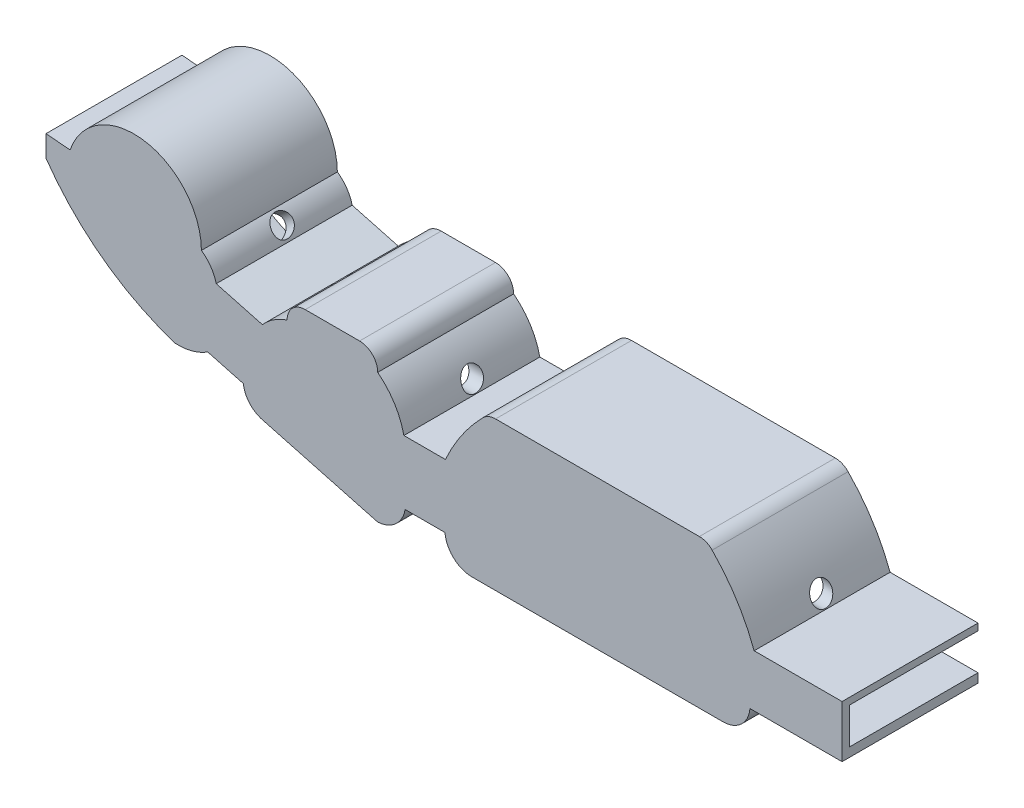
from build123d import *

# Parameters (mm, degrees)
WALLS_DEPTH         = 16
BASE_DEPTH          = 1
CUT_EXTRUDE2_START  = 3.037206
SKETCH14_R          = 1.4
CUT_EXTRUDE2_DEPTH  = 11.746553
CUT_EXTRUDE3_REACH  = 97.922
SKETCH15_R          = 1.4
CUT_EXTRUDE4_START  = -13.606104
SKETCH16_R          = 1.4
CUT_EXTRUDE4_DEPTH  = 14.101179
CUT_EXTRUDE5_REACH  = 79.266
SKETCH18_R          = 1.4
CUT_EXTRUDE6_DEPTH  = 1
CUT_EXTRUDE7_START  = 1
SKETCH20_W          = 0.5
SKETCH20_H          = 5.968950485
CUT_EXTRUDE7_DEPTH  = 13
CUT_EXTRUDE8_START  = -1
SKETCH21_W          = 1.2
SKETCH21_H          = 4.8
CUT_EXTRUDE8_DEPTH  = 17
BOSS_EXTRUDE7_DEPTH = 1


with BuildPart() as part:
    # Sketch1 → Walls (new body)
    with BuildSketch(Plane.XY):
        with BuildLine():
            Line((-2.714226626, -4.104973799), (9.481662569, -4.104973799))
            Line((9.481662569, -4.104973799), (9.481662569, 2.795026201))
            Line((9.481662569, 2.795026201), (-2.157765014, 2.795026201))
            ThreePointArc((-2.157765014, 2.795026201), (-4.475421171, 7.467506564), (-7.720187416, 11.551021571))
            ThreePointArc((-7.720187416, 11.551021571), (-8.494484922, 12.081481284), (-9.414311331, 12.268145448))
            Line((-9.414311331, 12.268145448), (-36.393543444, 12.262464463))
            ThreePointArc((-36.393543444, 12.262464463), (-37.313369853, 12.075800298), (-38.087667358, 11.545340586))
            ThreePointArc((-38.087667358, 11.545340586), (-40.886844781, 8.138526492), (-43.037560944, 4.289345216))
            Line((-43.037560944, 4.289345216), (-48.534846494, 4.289345216))
            ThreePointArc((-48.534846494, 4.289345216), (-49.785555134, 7.346558362), (-52.000729869, 9.796828799))
            ThreePointArc((-52.000729869, 9.796828799), (-52.703673594, 11.493885073), (-54.400729869, 12.196828799))
            Line((-54.400729869, 12.196828799), (-61.600729869, 12.196828799))
            ThreePointArc((-61.600729869, 12.196828799), (-63.297786144, 11.493885073), (-64.000729869, 9.796828799))
            ThreePointArc((-64.000729869, 9.796828799), (-65.78162874, 8.936932107), (-67.269416799, 7.634046924))
            Line((-67.269416799, 7.634046924), (-73.381930249, 9.274434959))
            ThreePointArc((-73.381930249, 9.274434959), (-74.102271118, 10.871911924), (-75.343349149, 12.109065488))
            ThreePointArc((-75.343349149, 12.109065488), (-82.839508973, 20.890555052), (-92.73395996, 14.940192817))
            Line((-92.73395996, 14.940192817), (-95.922420017, 15.211711628))
            Line((-95.922420017, 15.211711628), (-95.922420017, 12.380143838))
            ThreePointArc((-95.922420017, 12.380143838), (-88.403090993, 4.657382588), (-78.817826716, -0.272532121))
            ThreePointArc((-78.817826716, -0.272532121), (-76.571233378, -0.037510666), (-74.506694684, 0.879057219))
            Line((-74.506694684, 0.879057219), (-72.20946266, 0.262559283))
            Line((-72.20946266, 0.262559283), (-69.801914295, -0.383543758))
            ThreePointArc((-69.801914295, -0.383543758), (-68.910263869, -2.291103836), (-67.07577957, -3.324783328))
            Line((-67.07577957, -3.324783328), (-52.008906119, -7.36821311))
            ThreePointArc((-52.008906119, -7.36821311), (-49.620072822, -6.375064761), (-48.368947082, -4.110654784))
            Line((-48.368947082, -4.110654784), (-43.097948822, -4.110654784))
            ThreePointArc((-43.097948822, -4.110654784), (-41.950292784, -6.466194573), (-39.509720692, -7.419761527))
            Line((-39.509720692, -7.419761527), (-6.302454756, -7.414080542))
            ThreePointArc((-6.302454756, -7.414080542), (-3.861882663, -6.460513587), (-2.714226626, -4.104973799))
        make_face()
        with BuildLine():
            Line((-11.180694354, 10.652027), (-11.480694354, 9.152027))
            Line((-11.480694354, 9.152027), (-11.780694354, 10.652027))
            Line((-11.780694354, 10.652027), (-12.480694354, 10.652027))
            Line((-12.480694354, 10.652027), (-12.780694354, 9.152027))
            Line((-12.780694354, 9.152027), (-13.080694354, 10.652027))
            Line((-13.080694354, 10.652027), (-13.754684343, 10.652027))
            Line((-13.754684343, 10.652027), (-14.054684343, 9.152027))
            Line((-14.054684343, 9.152027), (-14.354684343, 10.652027))
            Line((-14.354684343, 10.652027), (-15.054684343, 10.652027))
            Line((-15.054684343, 10.652027), (-15.354684343, 9.152027))
            Line((-15.354684343, 9.152027), (-15.654684343, 10.652027))
            Line((-15.654684343, 10.652027), (-16.354684343, 10.652027))
            Line((-16.354684343, 10.652027), (-16.654684343, 9.152027))
            Line((-16.654684343, 9.152027), (-16.954684343, 10.652027))
            Line((-16.954684343, 10.652027), (-17.654684343, 10.652027))
            Line((-17.654684343, 10.652027), (-17.954684343, 9.152027))
            Line((-17.954684343, 9.152027), (-18.254684343, 10.652027))
            Line((-18.254684343, 10.652027), (-18.954684343, 10.652027))
            Line((-18.954684343, 10.652027), (-19.254684343, 9.152027))
            Line((-19.254684343, 9.152027), (-19.554684343, 10.652027))
            Line((-19.554684343, 10.652027), (-20.254684343, 10.652027))
            Line((-20.254684343, 10.652027), (-20.554684343, 9.152027))
            Line((-20.554684343, 9.152027), (-20.854684343, 10.652027))
            Line((-20.854684343, 10.652027), (-21.554684343, 10.652027))
            Line((-21.554684343, 10.652027), (-21.854684343, 9.152027))
            Line((-21.854684343, 9.152027), (-22.154684343, 10.652027))
            Line((-22.154684343, 10.652027), (-22.854684343, 10.652027))
            Line((-22.854684343, 10.652027), (-23.154684343, 9.152027))
            Line((-23.154684343, 9.152027), (-23.454684343, 10.652027))
            Line((-23.454684343, 10.652027), (-24.154684343, 10.652027))
            Line((-24.154684343, 10.652027), (-24.454684343, 9.152027))
            Line((-24.454684343, 9.152027), (-24.754684343, 10.652027))
            Line((-24.754684343, 10.652027), (-25.454684343, 10.652027))
            Line((-25.454684343, 10.652027), (-25.754684343, 9.152027))
            Line((-25.754684343, 9.152027), (-26.054684343, 10.652027))
            Line((-26.054684343, 10.652027), (-26.754684343, 10.652027))
            Line((-26.754684343, 10.652027), (-27.054684343, 9.152027))
            Line((-27.054684343, 9.152027), (-27.354684343, 10.652027))
            Line((-27.354684343, 10.652027), (-28.054684343, 10.652027))
            Line((-28.054684343, 10.652027), (-28.354684343, 9.152027))
            Line((-28.354684343, 9.152027), (-28.654684343, 10.652027))
            Line((-28.654684343, 10.652027), (-29.354684343, 10.652027))
            Line((-29.354684343, 10.652027), (-29.654684343, 9.152027))
            Line((-29.654684343, 9.152027), (-29.954684343, 10.652027))
            Line((-29.954684343, 10.652027), (-30.654684343, 10.652027))
            Line((-30.654684343, 10.652027), (-30.954684343, 9.152027))
            Line((-30.954684343, 9.152027), (-31.254684343, 10.652027))
            Line((-31.254684343, 10.652027), (-31.954684343, 10.652027))
            Line((-31.954684343, 10.652027), (-32.254684343, 9.152027))
            Line((-32.254684343, 9.152027), (-32.554684343, 10.652027))
            Line((-32.554684343, 10.652027), (-33.254684343, 10.652027))
            Line((-33.254684343, 10.652027), (-33.554684343, 9.152027))
            Line((-33.554684343, 9.152027), (-33.854684343, 10.652027))
            Line((-33.854684343, 10.652027), (-34.554684343, 10.652027))
            Line((-34.554684343, 10.652027), (-34.854684343, 9.152027))
            Line((-34.854684343, 9.152027), (-35.154684343, 10.652027))
            Line((-35.154684343, 10.652027), (-35.854684343, 10.652027))
            Line((-35.854684343, 10.652027), (-36.154684343, 9.152027))
            Line((-36.154684343, 9.152027), (-36.454684343, 10.652027))
            ThreePointArc((-36.454684343, 10.652027), (-37.292662775, 10.478146603), (-37.980497081, 9.968905783))
            ThreePointArc((-37.980497081, 9.968905783), (-38.339781414, 9.366609074), (-38.464845704, 8.676532642))
            ThreePointArc((-38.464845704, 8.676532642), (-40.888001005, 6.279206265), (-42.089517485, 3.089345216))
            Line((-42.089517485, 3.089345216), (-50.089517485, 3.089345216))
            ThreePointArc((-50.089517485, 3.089345216), (-51.291033964, 6.279206265), (-53.714189264, 8.676532642))
            ThreePointArc((-53.714189264, 8.676532642), (-54.299975702, 10.090746205), (-55.714189264, 10.676532642))
            Line((-55.714189264, 10.676532642), (-55.856345595, 10.676497632))
            Line((-55.856345595, 10.676497632), (-56.156345595, 9.176497632))
            Line((-56.156345595, 9.176497632), (-56.456345595, 10.676497632))
            Line((-56.456345595, 10.676497632), (-57.156345595, 10.676497632))
            Line((-57.156345595, 10.676497632), (-57.456345595, 9.176497632))
            Line((-57.456345595, 9.176497632), (-57.756345595, 10.676497632))
            Line((-57.756345595, 10.676497632), (-58.430335584, 10.676497632))
            Line((-58.430335584, 10.676497632), (-58.730335584, 9.176497632))
            Line((-58.730335584, 9.176497632), (-59.030335584, 10.676497632))
            Line((-59.030335584, 10.676497632), (-59.730335584, 10.676497632))
            Line((-59.730335584, 10.676497632), (-60.030335584, 9.176497632))
            Line((-60.030335584, 9.176497632), (-60.330335584, 10.676497632))
            Line((-60.330335584, 10.676497632), (-61.030335584, 10.676497632))
            Line((-61.030335584, 10.676497632), (-61.330335584, 9.176497632))
            Line((-61.330335584, 9.176497632), (-61.630335584, 10.676497632))
            Line((-61.630335584, 10.676497632), (-61.714189264, 10.676532642))
            ThreePointArc((-61.714189264, 10.676532642), (-63.128402827, 10.090746205), (-63.714189264, 8.676532642))
            ThreePointArc((-63.714189264, 8.676532642), (-65.500001958, 7.74697919), (-66.888810503, 6.289444483))
            Line((-66.888810503, 6.289444483), (-74.615412273, 8.362998217))
            ThreePointArc((-74.615412273, 8.362998217), (-75.168327877, 9.980217218), (-76.340301721, 11.22423903))
            ThreePointArc((-76.340301721, 11.22423903), (-76.479101675, 13.078813183), (-77.040301721, 14.851879798))
            Line((-77.040301721, 14.851879798), (-77.340301721, 12.851879798))
            Line((-77.340301721, 12.851879798), (-77.640301721, 15.949342028))
            ThreePointArc((-77.640301721, 15.949342028), (-77.973730307, 16.422192047), (-78.340301721, 16.869838292))
            Line((-78.340301721, 16.869838292), (-78.640301721, 15.669838292))
            Line((-78.640301721, 15.669838292), (-78.940301721, 17.481874263))
            ThreePointArc((-78.940301721, 17.481874263), (-79.282241901, 17.778086168), (-79.640301721, 18.054596106))
            Line((-79.640301721, 18.054596106), (-79.940301721, 16.954596106))
            Line((-79.940301721, 16.954596106), (-80.240301721, 18.451728481))
            ThreePointArc((-80.240301721, 18.451728481), (-80.585686051, 18.647304472), (-80.940301721, 18.825596453))
            Line((-80.940301721, 18.825596453), (-81.240301721, 17.825596453))
            Line((-81.240301721, 17.825596453), (-81.540301721, 19.079728683))
            ThreePointArc((-81.540301721, 19.079728683), (-81.887696099, 19.201527535), (-82.240301721, 19.307296578))
            Line((-82.240301721, 19.307296578), (-82.540301721, 18.257296578))
            Line((-82.540301721, 18.257296578), (-82.840301721, 19.447905416))
            ThreePointArc((-82.840301721, 19.447905416), (-83.189154152, 19.507733157), (-83.540301721, 19.552148937))
            Line((-83.540301721, 19.552148937), (-83.840301721, 18.452148937))
            Line((-83.840301721, 18.452148937), (-84.140301721, 19.592048122))
            ThreePointArc((-84.140301721, 19.592048122), (-84.491040143, 19.594566938), (-84.841554662, 19.581785774))
            Line((-84.841554662, 19.581785774), (-85.141554662, 18.391176936))
            Line((-85.141554662, 18.391176936), (-85.441554662, 19.524155456))
            ThreePointArc((-85.441554662, 19.524155456), (-85.791833752, 19.469314811), (-86.13935447, 19.399084563))
            Line((-86.13935447, 19.399084563), (-86.43935447, 18.141971888))
            Line((-86.43935447, 18.141971888), (-86.73935447, 19.239422428))
            ThreePointArc((-86.73935447, 19.239422428), (-87.091998465, 19.121847919), (-87.438830901, 18.988098851))
            Line((-87.438830901, 18.988098851), (-87.738830901, 17.688098851))
            Line((-87.738830901, 17.688098851), (-88.038830901, 18.71126671))
            ThreePointArc((-88.038830901, 18.71126671), (-88.392960603, 18.518509858), (-88.736981551, 18.308241846))
            Line((-88.736981551, 18.308241846), (-89.036981551, 16.808241846))
            Line((-89.036981551, 16.808241846), (-89.336981551, 17.880309155))
            ThreePointArc((-89.336981551, 17.880309155), (-89.696782022, 17.580609758), (-90.03852423, 17.260471709))
            Line((-90.03852423, 17.260471709), (-90.33852423, 15.360471709))
            Line((-90.33852423, 15.360471709), (-90.63852423, 16.594203768))
            ThreePointArc((-90.63852423, 16.594203768), (-91.742094902, 14.771493049), (-92.328110027, 12.722901125))
            ThreePointArc((-92.328110027, 12.722901125), (-92.734922926, 12.55653234), (-93.137492676, 12.380143838))
            Line((-93.137492676, 12.380143838), (-94.79525511, 13.498993117))
            Line((-94.79525511, 13.498993117), (-95.180932447, 13.939650809))
            Line((-95.180932447, 13.939650809), (-95.180932447, 13.203509547))
            Line((-95.180932447, 13.203509547), (-91.883433841, 9.259773044))
            ThreePointArc((-91.883433841, 9.259773044), (-86.176858956, 4.131509416), (-79.259737176, 0.812245789))
            ThreePointArc((-79.259737176, 0.812245789), (-77.207940067, 0.994602867), (-75.757412684, 2.457167667))
            Line((-75.757412684, 2.457167667), (-67.916777421, 0.353011271))
            ThreePointArc((-67.916777421, 0.353011271), (-67.293922784, -1.507170345), (-65.622743571, -2.534488982))
            Line((-65.622743571, -2.534488982), (-53.067015695, -5.904013801))
            ThreePointArc((-53.067015695, -5.904013801), (-51.049280095, -4.943204733), (-50.120220506, -2.910654784))
            Line((-50.120220506, -2.910654784), (-42.093838016, -2.910654784))
            ThreePointArc((-42.093838016, -2.910654784), (-41.323080809, -5.245314679), (-39.0658354, -6.219761527))
            Line((-39.0658354, -6.219761527), (-6.746340048, -6.214080542))
            ThreePointArc((-6.746340048, -6.214080542), (-4.489094638, -5.239633694), (-3.718337431, -2.904973799))
            Line((-3.718337431, -2.904973799), (8.281662569, -2.904973799))
            Line((8.281662569, -2.904973799), (8.281662569, 1.895026201))
            Line((8.281662569, 1.895026201), (-3.634781843, 1.895026201))
            ThreePointArc((-3.634781843, 1.895026201), (-4.611558125, 5.76795929), (-7.34300907, 8.682213628))
            ThreePointArc((-7.34300907, 8.682213628), (-8.12308073, 9.896738229), (-9.353170431, 10.652027))
            Line((-9.353170431, 10.652027), (-9.906704364, 10.652027))
            Line((-9.906704364, 10.652027), (-10.206704364, 9.152027))
            Line((-10.206704364, 9.152027), (-10.506704364, 10.652027))
            Line((-10.506704364, 10.652027), (-11.180694354, 10.652027))
        make_face(mode=Mode.SUBTRACT)
    extrude(amount=WALLS_DEPTH)

    # Sketch2 → Base (add)
    with BuildSketch(Plane(origin=(0, 0, 0), x_dir=(-1, 0, 0), z_dir=(0, 0, -1))):
        with BuildLine():
            Line((95.922420017, 15.211711628), (95.922420017, 12.380143838))
            ThreePointArc((95.922420017, 12.380143838), (88.403090993, 4.657382588), (78.817826716, -0.272532121))
            ThreePointArc((78.817826716, -0.272532121), (76.571233378, -0.037510666), (74.506694684, 0.879057219))
            Line((74.506694684, 0.879057219), (72.20946266, 0.262559283))
            Line((72.20946266, 0.262559283), (69.801914295, -0.383543758))
            ThreePointArc((69.801914295, -0.383543758), (68.910263869, -2.291103836), (67.07577957, -3.324783328))
            Line((67.07577957, -3.324783328), (52.008906119, -7.36821311))
            ThreePointArc((52.008906119, -7.36821311), (49.620072822, -6.375064761), (48.368947082, -4.110654784))
            Line((48.368947082, -4.110654784), (43.097948822, -4.110654784))
            ThreePointArc((43.097948822, -4.110654784), (41.950066404, -6.466403325), (39.509104816, -7.419761475))
            Line((39.509104816, -7.419761475), (6.30183888, -7.414080489))
            ThreePointArc((6.30183888, -7.414080489), (3.861656301, -6.460304815), (2.714226626, -4.104973799))
            Line((2.714226626, -4.104973799), (-9.481662569, -4.104973799))
            Line((-9.481662569, -4.104973799), (-9.481662569, 2.795026201))
            Line((-9.481662569, 2.795026201), (2.157765014, 2.795026201))
            ThreePointArc((2.157765014, 2.795026201), (4.475421171, 7.467506564), (7.720187416, 11.551021571))
            ThreePointArc((7.720187416, 11.551021571), (8.494484922, 12.081481284), (9.414311331, 12.268145448))
            Line((9.414311331, 12.268145448), (36.393543444, 12.262464463))
            ThreePointArc((36.393543444, 12.262464463), (37.313369853, 12.075800298), (38.087667358, 11.545340586))
            ThreePointArc((38.087667358, 11.545340586), (40.886844781, 8.138526492), (43.037560944, 4.289345216))
            Line((43.037560944, 4.289345216), (48.534846494, 4.289345216))
            ThreePointArc((48.534846494, 4.289345216), (49.785555134, 7.346558362), (52.000729869, 9.796828799))
            ThreePointArc((52.000729869, 9.796828799), (52.703673594, 11.493885073), (54.400729869, 12.196828799))
            Line((54.400729869, 12.196828799), (61.600729869, 12.196828799))
            ThreePointArc((61.600729869, 12.196828799), (63.297786144, 11.493885073), (64.000729869, 9.796828799))
            ThreePointArc((64.000729869, 9.796828799), (65.78162874, 8.936932107), (67.269416799, 7.634046924))
            Line((67.269416799, 7.634046924), (73.381930249, 9.274434959))
            ThreePointArc((73.381930249, 9.274434959), (74.102271118, 10.871911924), (75.343349149, 12.109065488))
            ThreePointArc((75.343349149, 12.109065488), (82.839508973, 20.890555052), (92.73395996, 14.940192817))
            Line((92.73395996, 14.940192817), (95.922420017, 15.211711628))
        make_face()
    extrude(amount=BASE_DEPTH)

    # Sketch14 → Cut-Extrude2 (cut)
    with BuildSketch(Plane(origin=(-55, 0, 0), x_dir=(0, 0, -1), z_dir=(1, 0, 0)).offset(CUT_EXTRUDE2_START)):
        with Locations((-7.5, 5.771124661)):
            Circle(SKETCH14_R)
    extrude(amount=CUT_EXTRUDE2_DEPTH, mode=Mode.SUBTRACT)

    # Sketch15 → Cut-Extrude3 (cut, up to next)
    with BuildSketch(Plane(origin=(0, 0, 0), x_dir=(0, 0, -1), z_dir=(1, 0, 0)), mode=Mode.PRIVATE) as cut_extrude3_sk1:
        with Locations((-7.5, 4.295026201)):
            Circle(SKETCH15_R)
    cut_extrude3_tool1 = extrude(cut_extrude3_sk1.sketch, amount=-CUT_EXTRUDE3_REACH, mode=Mode.PRIVATE) & part.part
    add(cut_extrude3_tool1.solids().sort_by_distance((0, 4.295026, 7.5))[0], mode=Mode.SUBTRACT)

    # Sketch16 → Cut-Extrude4 (cut)
    with BuildSketch(Plane(origin=(-38.524212099, -32.300160788, 0), x_dir=(0, 0, -1), z_dir=(0.766294061, 0.642490009, 0)).offset(CUT_EXTRUDE4_START)):
        with Locations((-7.5, 55.970277762)):
            Circle(SKETCH16_R)
    extrude(amount=CUT_EXTRUDE4_DEPTH, mode=Mode.SUBTRACT)

    # Sketch18 → Cut-Extrude5 (cut, up to next)
    with BuildSketch(Plane(origin=(-61.83939272, 22.534904209, 0), x_dir=(0, 0, -1), z_dir=(-0.9395597, 0.342385119, 0)), mode=Mode.PRIVATE) as cut_extrude5_sk1:
        with Locations((-7.5, 14.283191991)):
            Circle(SKETCH18_R)
    cut_extrude5_tool1 = extrude(cut_extrude5_sk1.sketch, amount=-CUT_EXTRUDE5_REACH, mode=Mode.PRIVATE) & part.part
    add(cut_extrude5_tool1.solids().sort_by_distance((-66.729745, 9.114993, 7.5))[0], mode=Mode.SUBTRACT)

    # Sketch19 → Cut-Extrude6 (cut)
    with BuildSketch(Plane.XY):
        with BuildLine():
            Line((-11.180694354, 10.652027), (-11.480694354, 9.152027))
            Line((-11.480694354, 9.152027), (-11.780694354, 10.652027))
            Line((-11.780694354, 10.652027), (-12.480694354, 10.652027))
            Line((-12.480694354, 10.652027), (-12.780694354, 9.152027))
            Line((-12.780694354, 9.152027), (-13.080694354, 10.652027))
            Line((-13.080694354, 10.652027), (-13.754684343, 10.652027))
            Line((-13.754684343, 10.652027), (-14.054684343, 9.152027))
            Line((-14.054684343, 9.152027), (-14.354684343, 10.652027))
            Line((-14.354684343, 10.652027), (-15.054684343, 10.652027))
            Line((-15.054684343, 10.652027), (-15.354684343, 9.152027))
            Line((-15.354684343, 9.152027), (-15.654684343, 10.652027))
            Line((-15.654684343, 10.652027), (-16.354684343, 10.652027))
            Line((-16.354684343, 10.652027), (-16.654684343, 9.152027))
            Line((-16.654684343, 9.152027), (-16.954684343, 10.652027))
            Line((-16.954684343, 10.652027), (-17.654684343, 10.652027))
            Line((-17.654684343, 10.652027), (-17.954684343, 9.152027))
            Line((-17.954684343, 9.152027), (-18.254684343, 10.652027))
            Line((-18.254684343, 10.652027), (-18.954684343, 10.652027))
            Line((-18.954684343, 10.652027), (-19.254684343, 9.152027))
            Line((-19.254684343, 9.152027), (-19.554684343, 10.652027))
            Line((-19.554684343, 10.652027), (-20.254684343, 10.652027))
            Line((-20.254684343, 10.652027), (-20.554684343, 9.152027))
            Line((-20.554684343, 9.152027), (-20.854684343, 10.652027))
            Line((-20.854684343, 10.652027), (-21.554684343, 10.652027))
            Line((-21.554684343, 10.652027), (-21.854684343, 9.152027))
            Line((-21.854684343, 9.152027), (-22.154684343, 10.652027))
            Line((-22.154684343, 10.652027), (-22.854684343, 10.652027))
            Line((-22.854684343, 10.652027), (-23.154684343, 9.152027))
            Line((-23.154684343, 9.152027), (-23.454684343, 10.652027))
            Line((-23.454684343, 10.652027), (-24.154684343, 10.652027))
            Line((-24.154684343, 10.652027), (-24.454684343, 9.152027))
            Line((-24.454684343, 9.152027), (-24.754684343, 10.652027))
            Line((-24.754684343, 10.652027), (-25.454684343, 10.652027))
            Line((-25.454684343, 10.652027), (-25.754684343, 9.152027))
            Line((-25.754684343, 9.152027), (-26.054684343, 10.652027))
            Line((-26.054684343, 10.652027), (-26.754684343, 10.652027))
            Line((-26.754684343, 10.652027), (-27.054684343, 9.152027))
            Line((-27.054684343, 9.152027), (-27.354684343, 10.652027))
            Line((-27.354684343, 10.652027), (-28.054684343, 10.652027))
            Line((-28.054684343, 10.652027), (-28.354684343, 9.152027))
            Line((-28.354684343, 9.152027), (-28.654684343, 10.652027))
            Line((-28.654684343, 10.652027), (-29.354684343, 10.652027))
            Line((-29.354684343, 10.652027), (-29.654684343, 9.152027))
            Line((-29.654684343, 9.152027), (-29.954684343, 10.652027))
            Line((-29.954684343, 10.652027), (-30.654684343, 10.652027))
            Line((-30.654684343, 10.652027), (-30.954684343, 9.152027))
            Line((-30.954684343, 9.152027), (-31.254684343, 10.652027))
            Line((-31.254684343, 10.652027), (-31.954684343, 10.652027))
            Line((-31.954684343, 10.652027), (-32.254684343, 9.152027))
            Line((-32.254684343, 9.152027), (-32.554684343, 10.652027))
            Line((-32.554684343, 10.652027), (-33.254684343, 10.652027))
            Line((-33.254684343, 10.652027), (-33.554684343, 9.152027))
            Line((-33.554684343, 9.152027), (-33.854684343, 10.652027))
            Line((-33.854684343, 10.652027), (-34.554684343, 10.652027))
            Line((-34.554684343, 10.652027), (-34.854684343, 9.152027))
            Line((-34.854684343, 9.152027), (-35.154684343, 10.652027))
            Line((-35.154684343, 10.652027), (-35.854684343, 10.652027))
            Line((-35.854684343, 10.652027), (-36.154684343, 9.152027))
            Line((-36.154684343, 9.152027), (-36.454684343, 10.652027))
            ThreePointArc((-36.454684343, 10.652027), (-37.292662775, 10.478146603), (-37.980497081, 9.968905783))
            ThreePointArc((-37.980497081, 9.968905783), (-38.339781414, 9.366609074), (-38.464845704, 8.676532642))
            ThreePointArc((-38.464845704, 8.676532642), (-40.888001005, 6.279206265), (-42.089517485, 3.089345216))
            Line((-42.089517485, 3.089345216), (-50.089517485, 3.089345216))
            ThreePointArc((-50.089517485, 3.089345216), (-51.291033964, 6.279206265), (-53.714189264, 8.676532642))
            ThreePointArc((-53.714189264, 8.676532642), (-54.299975702, 10.090746205), (-55.714189264, 10.676532642))
            Line((-55.714189264, 10.676532642), (-55.856345595, 10.676497632))
            Line((-55.856345595, 10.676497632), (-56.156345595, 9.176497632))
            Line((-56.156345595, 9.176497632), (-56.456345595, 10.676497632))
            Line((-56.456345595, 10.676497632), (-57.156345595, 10.676497632))
            Line((-57.156345595, 10.676497632), (-57.456345595, 9.176497632))
            Line((-57.456345595, 9.176497632), (-57.756345595, 10.676497632))
            Line((-57.756345595, 10.676497632), (-58.430335584, 10.676497632))
            Line((-58.430335584, 10.676497632), (-58.730335584, 9.176497632))
            Line((-58.730335584, 9.176497632), (-59.030335584, 10.676497632))
            Line((-59.030335584, 10.676497632), (-59.730335584, 10.676497632))
            Line((-59.730335584, 10.676497632), (-60.030335584, 9.176497632))
            Line((-60.030335584, 9.176497632), (-60.330335584, 10.676497632))
            Line((-60.330335584, 10.676497632), (-61.030335584, 10.676497632))
            Line((-61.030335584, 10.676497632), (-61.330335584, 9.176497632))
            Line((-61.330335584, 9.176497632), (-61.630335584, 10.676497632))
            Line((-61.630335584, 10.676497632), (-61.714189264, 10.676532642))
            ThreePointArc((-61.714189264, 10.676532642), (-63.128402827, 10.090746205), (-63.714189264, 8.676532642))
            ThreePointArc((-63.714189264, 8.676532642), (-65.500001958, 7.74697919), (-66.888810503, 6.289444483))
            Line((-66.888810503, 6.289444483), (-74.615412273, 8.362998217))
            ThreePointArc((-74.615412273, 8.362998217), (-75.168327877, 9.980217218), (-76.340301721, 11.22423903))
            ThreePointArc((-76.340301721, 11.22423903), (-76.479101675, 13.078813183), (-77.040301721, 14.851879798))
            Line((-77.040301721, 14.851879798), (-77.340301721, 12.851879798))
            Line((-77.340301721, 12.851879798), (-77.640301721, 15.949342028))
            ThreePointArc((-77.640301721, 15.949342028), (-77.973730307, 16.422192047), (-78.340301721, 16.869838292))
            Line((-78.340301721, 16.869838292), (-78.640301721, 15.669838292))
            Line((-78.640301721, 15.669838292), (-78.940301721, 17.481874263))
            ThreePointArc((-78.940301721, 17.481874263), (-79.282241901, 17.778086168), (-79.640301721, 18.054596106))
            Line((-79.640301721, 18.054596106), (-79.940301721, 16.954596106))
            Line((-79.940301721, 16.954596106), (-80.240301721, 18.451728481))
            ThreePointArc((-80.240301721, 18.451728481), (-80.585686051, 18.647304472), (-80.940301721, 18.825596453))
            Line((-80.940301721, 18.825596453), (-81.240301721, 17.825596453))
            Line((-81.240301721, 17.825596453), (-81.540301721, 19.079728683))
            ThreePointArc((-81.540301721, 19.079728683), (-81.887696099, 19.201527535), (-82.240301721, 19.307296578))
            Line((-82.240301721, 19.307296578), (-82.540301721, 18.257296578))
            Line((-82.540301721, 18.257296578), (-82.840301721, 19.447905416))
            ThreePointArc((-82.840301721, 19.447905416), (-83.189154152, 19.507733157), (-83.540301721, 19.552148937))
            Line((-83.540301721, 19.552148937), (-83.840301721, 18.452148937))
            Line((-83.840301721, 18.452148937), (-84.140301721, 19.592048122))
            ThreePointArc((-84.140301721, 19.592048122), (-84.491040143, 19.594566938), (-84.841554662, 19.581785774))
            Line((-84.841554662, 19.581785774), (-85.141554662, 18.391176936))
            Line((-85.141554662, 18.391176936), (-85.441554662, 19.524155456))
            ThreePointArc((-85.441554662, 19.524155456), (-85.791833752, 19.469314811), (-86.13935447, 19.399084563))
            Line((-86.13935447, 19.399084563), (-86.43935447, 18.141971888))
            Line((-86.43935447, 18.141971888), (-86.73935447, 19.239422428))
            ThreePointArc((-86.73935447, 19.239422428), (-87.091998465, 19.121847919), (-87.438830901, 18.988098851))
            Line((-87.438830901, 18.988098851), (-87.738830901, 17.688098851))
            Line((-87.738830901, 17.688098851), (-88.038830901, 18.71126671))
            ThreePointArc((-88.038830901, 18.71126671), (-88.392960603, 18.518509858), (-88.736981551, 18.308241846))
            Line((-88.736981551, 18.308241846), (-89.036981551, 16.808241846))
            Line((-89.036981551, 16.808241846), (-89.336981551, 17.880309155))
            ThreePointArc((-89.336981551, 17.880309155), (-89.696782022, 17.580609758), (-90.03852423, 17.260471709))
            Line((-90.03852423, 17.260471709), (-90.33852423, 15.360471709))
            Line((-90.33852423, 15.360471709), (-90.63852423, 16.594203768))
            ThreePointArc((-90.63852423, 16.594203768), (-91.742094902, 14.771493049), (-92.328110027, 12.722901125))
            ThreePointArc((-92.328110027, 12.722901125), (-92.734922926, 12.55653234), (-93.137492676, 12.380143838))
            Line((-93.137492676, 12.380143838), (-94.79525511, 13.498993117))
            Line((-94.79525511, 13.498993117), (-95.180932447, 13.939650809))
            Line((-95.180932447, 13.939650809), (-95.180932447, 13.203509547))
            Line((-95.180932447, 13.203509547), (-91.883433841, 9.259773044))
            ThreePointArc((-91.883433841, 9.259773044), (-86.176858956, 4.131509416), (-79.259737176, 0.812245789))
            ThreePointArc((-79.259737176, 0.812245789), (-77.207940067, 0.994602867), (-75.757412684, 2.457167667))
            Line((-75.757412684, 2.457167667), (-67.916777421, 0.353011271))
            ThreePointArc((-67.916777421, 0.353011271), (-67.293922784, -1.507170345), (-65.622743571, -2.534488982))
            Line((-65.622743571, -2.534488982), (-53.067015695, -5.904013801))
            ThreePointArc((-53.067015695, -5.904013801), (-51.049280095, -4.943204733), (-50.120220506, -2.910654784))
            Line((-50.120220506, -2.910654784), (-42.093838016, -2.910654784))
            ThreePointArc((-42.093838016, -2.910654784), (-41.323080809, -5.245314679), (-39.0658354, -6.219761527))
            Line((-39.0658354, -6.219761527), (-6.746340048, -6.214080542))
            ThreePointArc((-6.746340048, -6.214080542), (-4.489094638, -5.239633694), (-3.718337431, -2.904973799))
            Line((-3.718337431, -2.904973799), (8.281662569, -2.904973799))
            Line((8.281662569, -2.904973799), (8.281662569, 1.895026201))
            Line((8.281662569, 1.895026201), (-3.634781843, 1.895026201))
            ThreePointArc((-3.634781843, 1.895026201), (-4.611558125, 5.76795929), (-7.34300907, 8.682213628))
            ThreePointArc((-7.34300907, 8.682213628), (-8.12308073, 9.896738229), (-9.353170431, 10.652027))
            Line((-9.353170431, 10.652027), (-9.906704364, 10.652027))
            Line((-9.906704364, 10.652027), (-10.206704364, 9.152027))
            Line((-10.206704364, 9.152027), (-10.506704364, 10.652027))
            Line((-10.506704364, 10.652027), (-11.180694354, 10.652027))
        make_face()
    extrude(amount=-CUT_EXTRUDE6_DEPTH, mode=Mode.SUBTRACT)

    # Sketch20 → Cut-Extrude7 (cut)
    with BuildSketch(Plane.XY.offset(CUT_EXTRUDE7_START)):
        Polygon((-92.772285145, 5.921211801), (-90.293318424, 8.338328912), (-89.959048276, 7.965917677), (-92.423225856, 5.563220722), align=None)
        Polygon((-60.527542753, -7.088554524), (-59.440007817, -3.036115845), (-58.957095207, -3.165712953), (-60.044630142, -7.218151633), align=None)
        Polygon((-81.051799548, 2.093170067), (-82.083381187, -0.642254379), (-81.61554339, -0.81868509), (-80.583961751, 1.916739355), align=None)
        with Locations((-24.497959011, -7.165975116)):
            Rectangle(SKETCH20_W, SKETCH20_H)
    extrude(amount=CUT_EXTRUDE7_DEPTH, mode=Mode.SUBTRACT)

    # Sketch21 → Cut-Extrude8 (cut)
    with BuildSketch(Plane.XY.offset(CUT_EXTRUDE8_START)):
        with Locations((8.881662569, -0.504973799)):
            Rectangle(SKETCH21_W, SKETCH21_H)
    extrude(amount=CUT_EXTRUDE8_DEPTH, mode=Mode.SUBTRACT)

    # Sketch22 → Boss-Extrude7 (add)
    with BuildSketch(Plane.XY.offset(16)):
        with BuildLine():
            Line((-2.714226626, -4.104973799), (9.481662569, -4.104973799))
            Line((9.481662569, -4.104973799), (9.481662569, 2.795026201))
            Line((9.481662569, 2.795026201), (-2.157765014, 2.795026201))
            ThreePointArc((-2.157765014, 2.795026201), (-4.475421171, 7.467506564), (-7.720187416, 11.551021571))
            ThreePointArc((-7.720187416, 11.551021571), (-8.494713708, 12.081578115), (-9.4148082, 12.268145396))
            Line((-9.4148082, 12.268145396), (-36.394040312, 12.26246441))
            ThreePointArc((-36.394040312, 12.26246441), (-37.313598629, 12.075703443), (-38.087667358, 11.545340586))
            ThreePointArc((-38.087667358, 11.545340586), (-40.886844781, 8.138526492), (-43.037560944, 4.289345216))
            Line((-43.037560944, 4.289345216), (-48.534846494, 4.289345216))
            ThreePointArc((-48.534846494, 4.289345216), (-49.785555134, 7.346558362), (-52.000729869, 9.796828799))
            ThreePointArc((-52.000729869, 9.796828799), (-52.703673594, 11.493885073), (-54.400729869, 12.196828799))
            Line((-54.400729869, 12.196828799), (-61.600729869, 12.196828799))
            ThreePointArc((-61.600729869, 12.196828799), (-63.297786144, 11.493885073), (-64.000729869, 9.796828799))
            ThreePointArc((-64.000729869, 9.796828799), (-65.78162874, 8.936932107), (-67.269416799, 7.634046924))
            Line((-67.269416799, 7.634046924), (-73.381930249, 9.274434959))
            ThreePointArc((-73.381930249, 9.274434959), (-74.102271118, 10.871911924), (-75.343349149, 12.109065488))
            ThreePointArc((-75.343349149, 12.109065488), (-82.839508973, 20.890555052), (-92.73395996, 14.940192817))
            Line((-92.73395996, 14.940192817), (-95.922420017, 15.211711628))
            Line((-95.922420017, 15.211711628), (-95.922420017, 12.380143838))
            ThreePointArc((-95.922420017, 12.380143838), (-88.403090993, 4.657382588), (-78.817826716, -0.272532121))
            ThreePointArc((-78.817826716, -0.272532121), (-76.571233378, -0.037510666), (-74.506694684, 0.879057219))
            Line((-74.506694684, 0.879057219), (-72.20946266, 0.262559283))
            Line((-72.20946266, 0.262559283), (-69.801914295, -0.383543758))
            ThreePointArc((-69.801914295, -0.383543758), (-68.910263869, -2.291103836), (-67.07577957, -3.324783328))
            Line((-67.07577957, -3.324783328), (-52.008906119, -7.36821311))
            ThreePointArc((-52.008906119, -7.36821311), (-49.620072822, -6.375064761), (-48.368947082, -4.110654784))
            Line((-48.368947082, -4.110654784), (-43.097948822, -4.110654784))
            ThreePointArc((-43.097948822, -4.110654784), (-41.950066404, -6.466403325), (-39.509104816, -7.419761475))
            Line((-39.509104816, -7.419761475), (-6.30183888, -7.414080489))
            ThreePointArc((-6.30183888, -7.414080489), (-3.861656301, -6.460304815), (-2.714226626, -4.104973799))
        make_face()
    extrude(amount=BOSS_EXTRUDE7_DEPTH)


solid = part.part
